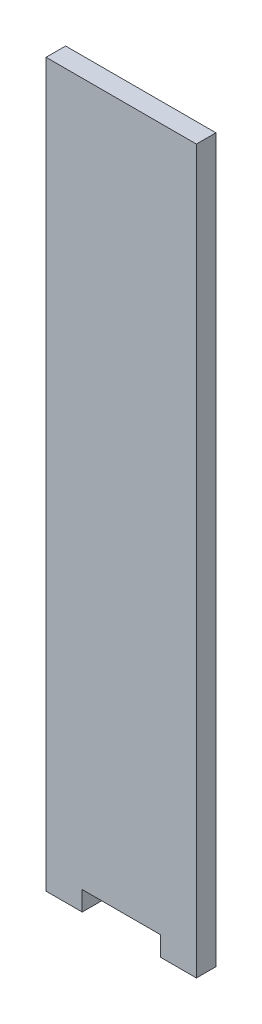
from build123d import *

# Parameters (mm, degrees)
BOSS_EXTRUDE1_DEPTH = 5


with BuildPart() as part:
    # Sketch1 → Boss-Extrude1 (new body)
    with BuildSketch(Plane.XY):
        Polygon((-19.25, 180), (19.25, 180), (19.25, 0), (19.25, -5), (10, -5), (10, 0), (-10, 0), (-10, -5), (-19.25, -5), (-19.25, 0), align=None)
    extrude(amount=BOSS_EXTRUDE1_DEPTH)


solid = part.part
